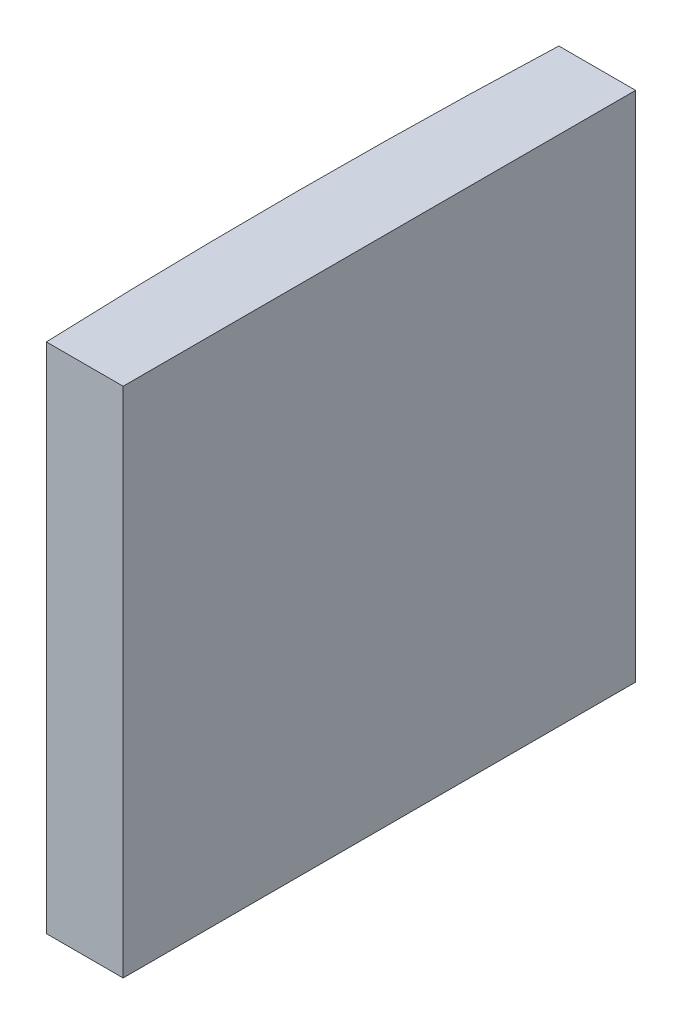
from build123d import *

# Parameters (mm, degrees)
EXTRUDE_1_DEPTH = 20


with BuildPart() as part:
    # 草图1 → 凸台-拉伸1 (new body)
    with BuildSketch(Plane(origin=(0, 0, 0), x_dir=(1, 0, 0), z_dir=(0, 1, 0))):
        with BuildLine():
            Line((-253.951299648, 10), (-250.954795665, 10))
            Line((-250.954795665, 10), (-250.954795665, -10))
            Line((-250.954795665, -10), (-253.951299648, -10))
            ThreePointArc((-253.951299648, -10), (-254.144795665, 0), (-253.951299648, 10))
        make_face()
    extrude(amount=EXTRUDE_1_DEPTH)


solid = part.part
